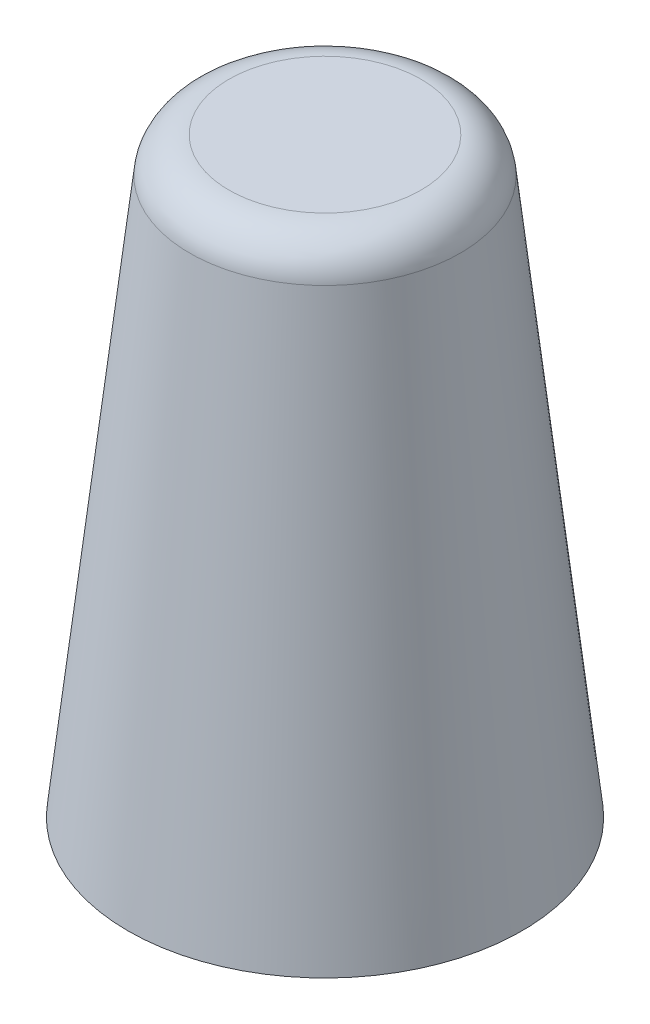
from build123d import *


with BuildPart() as part:
    # Эскиз1 → Повернуть1 (revolve)
    with BuildSketch(Plane.XY):
        with BuildLine():
            Line((0, 0), (0, 45))
            Line((0, 45), (7.314871621, 45))
            ThreePointArc((7.314871621, 45), (9.315636008, 44.235384054), (10.296522825, 42.331294578))
            Line((10.296522825, 42.331294578), (15, 0))
            Line((15, 0), (0, 0))
        make_face()
    revolve(axis=Axis((0, 0, 0), (0, 1, 0)))


solid = part.part
